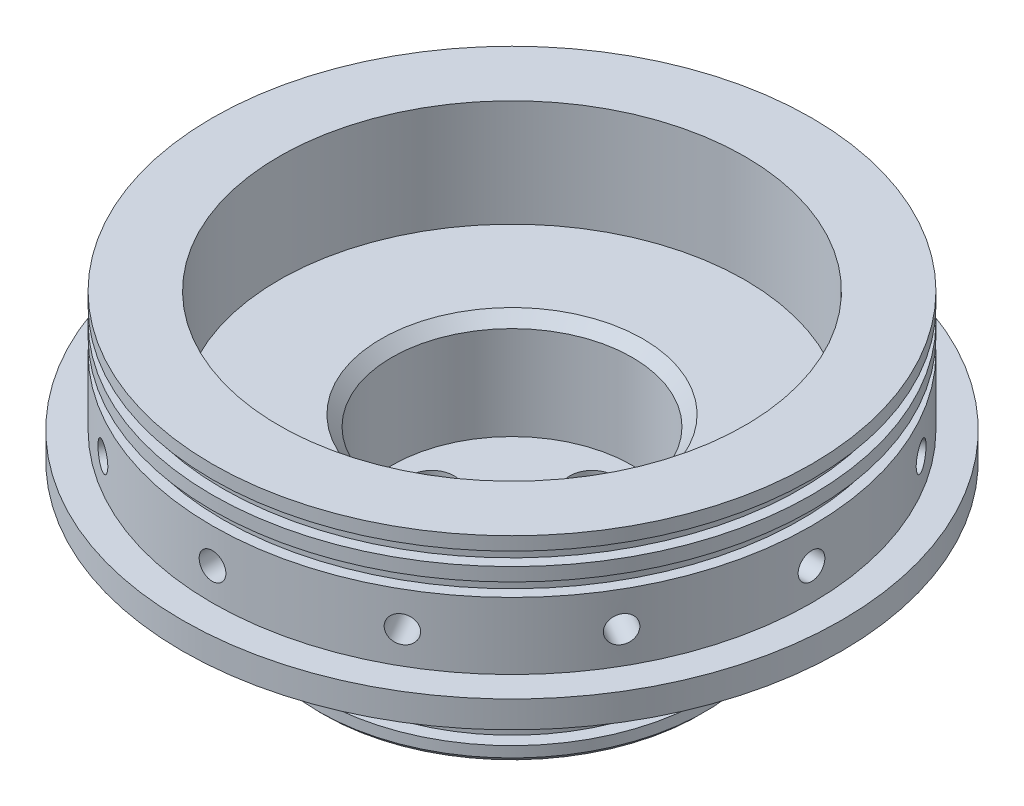
from build123d import *

# Parameters (mm, degrees)
SKETCH4_R                         = 3.175
CUT_EXTRUDE1_DEPTH                = 9.525
CIRPATTERN1_COUNT                 = 12
SKETCH5_R                         = 2.413
CUT_EXTRUDE2_DEPTH                = 9.525
CIRPATTERN2_COUNT                 = 12
F_1_8_NPT_TAPPED_HOLE1_AT_2_COUNT = 2
F_1_8_NPT_TAPPED_HOLE1_AT_2_PITCH = 26.940768363
F_1_8_NPT_TAPPED_HOLE1_AT_3_COUNT = 2
F_1_8_NPT_TAPPED_HOLE1_AT_3_PITCH = 38.1
F_1_8_NPT_TAPPED_HOLE1_AT_4_COUNT = 2
F_1_8_NPT_TAPPED_HOLE1_AT_4_PITCH = 26.940768363
F_1_8_NPT_TAPPED_HOLE1_AT_5_COUNT = 2
F_1_8_NPT_TAPPED_HOLE1_AT_5_PITCH = 19.05
CHAMFER1_SIZE                     = 2.54
CHAMFER2_SIZE                     = 1.27


with BuildPart() as part:
    # Sketch1 → Revolve1 (revolve)
    with BuildSketch(Plane.XY):
        Polygon((0, 0), (-45.847, 0), (-45.847, 3.81), (-42.828244544, 3.81), (-42.828244544, 10.9982), (-45.847, 10.9982), (-45.847, 14.8082), (-45.847, 30.0482), (-71.247, 30.0482), (-78.359, 30.0482), (-78.359, 36.3982), (-71.247, 36.3982), (-71.247, 49.0982), (-71.247, 52.2732), (-68.707, 52.2732), (-68.707, 55.4482), (-71.247, 55.4482), (-71.247, 58.6232), (-68.707, 58.6232), (-68.707, 61.7982), (-71.247, 61.7982), (-71.247, 64.9732), (-55.372, 64.9732), (-55.372, 39.5732), (-28.575, 39.5732), (-28.575, 30.0482), (-28.575, 14.8082), (0, 14.8082), align=None)
    revolve(axis=Axis((0, 0, 0), (0, 1, 0)))

    # Sketch4 → Cut-Extrude1 (cut)
    with BuildSketch(Plane.XY.offset(71.247)):
        with Locations((0, 44.0182)):
            Circle(SKETCH4_R)
    cut_extrude1 = extrude(amount=-CUT_EXTRUDE1_DEPTH, mode=Mode.SUBTRACT)

    # CirPattern1: Cut-Extrude1 ×12 about axis
    cirpattern1_axis = Axis((0, 0, 0), (0, -1, 0))
    for i in range(1, CIRPATTERN1_COUNT):
        add(cut_extrude1.rotate(cirpattern1_axis, i * 360 / CIRPATTERN1_COUNT), mode=Mode.SUBTRACT)

    # Sketch5 → Cut-Extrude2 (cut)
    with BuildSketch(Plane.XY.offset(45.847)):
        with Locations((0, 22.4282)):
            Circle(SKETCH5_R)
    cut_extrude2 = extrude(amount=-CUT_EXTRUDE2_DEPTH, mode=Mode.SUBTRACT)

    # CirPattern2: Cut-Extrude2 ×12 about axis
    cirpattern2_axis = Axis((0, 0, 0), (0, -1, 0))
    for i in range(1, CIRPATTERN2_COUNT):
        add(cut_extrude2.rotate(cirpattern2_axis, i * 360 / CIRPATTERN2_COUNT), mode=Mode.SUBTRACT)

    # Sketch10 → 1_8 NPT Tapped Hole1 (revolve, cut)
    with BuildSketch(Plane(origin=(-19.05, 0, 0), x_dir=(0, 0, -1), z_dir=(1, 0, 0))):
        Polygon((0, 0), (0, 64.9732), (4.2164, 64.9732), (4.2164, 25.4), (4.936189285, 25.4), (5.6966993, 0), align=None)
    f_1_8_npt_tapped_hole1 = revolve(axis=Axis((-19.05, -6.35, 0), (0, 1, 0)), mode=Mode.SUBTRACT)

    # 1_8 NPT Tapped Hole1 at 2: 1_8 NPT Tapped Hole1 ×2
    with Locations(*[Vector(0.7071067811865477, 0, -0.7071067811865474) * (i * F_1_8_NPT_TAPPED_HOLE1_AT_2_PITCH) for i in range(1, F_1_8_NPT_TAPPED_HOLE1_AT_2_COUNT)]):
        add(f_1_8_npt_tapped_hole1, mode=Mode.SUBTRACT)

    # 1_8 NPT Tapped Hole1 at 3: 1_8 NPT Tapped Hole1 ×2
    with Locations(*[(i * F_1_8_NPT_TAPPED_HOLE1_AT_3_PITCH, 0, 0) for i in range(1, F_1_8_NPT_TAPPED_HOLE1_AT_3_COUNT)]):
        add(f_1_8_npt_tapped_hole1, mode=Mode.SUBTRACT)

    # 1_8 NPT Tapped Hole1 at 4: 1_8 NPT Tapped Hole1 ×2
    with Locations(*[Vector(0.7071067811865475, 0, 0.7071067811865477) * (i * F_1_8_NPT_TAPPED_HOLE1_AT_4_PITCH) for i in range(1, F_1_8_NPT_TAPPED_HOLE1_AT_4_COUNT)]):
        add(f_1_8_npt_tapped_hole1, mode=Mode.SUBTRACT)

    # 1_8 NPT Tapped Hole1 at 5: 1_8 NPT Tapped Hole1 ×2
    with Locations(*[(i * F_1_8_NPT_TAPPED_HOLE1_AT_5_PITCH, 0, 0) for i in range(1, F_1_8_NPT_TAPPED_HOLE1_AT_5_COUNT)]):
        add(f_1_8_npt_tapped_hole1, mode=Mode.SUBTRACT)

    # Chamfer1
    chamfer1_edges = [part.edges().sort_by_distance(p)[0] for p in [
        (28.575, 39.5732, 0),
    ]]
    chamfer(chamfer1_edges, length=CHAMFER1_SIZE)

    # Chamfer2
    chamfer2_edges = [part.edges().sort_by_distance(p)[0] for p in [
        (45.847, 0, 0),
    ]]
    chamfer(chamfer2_edges, length=CHAMFER2_SIZE)


solid = part.part
